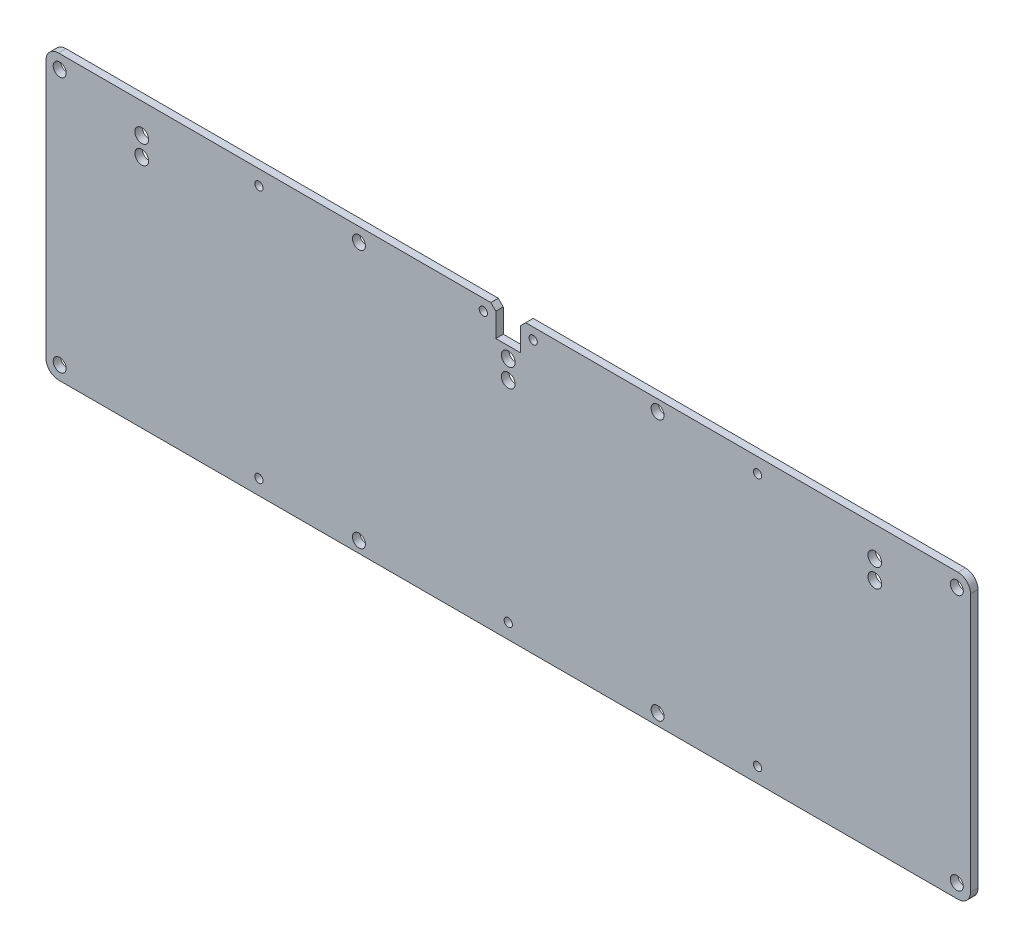
from build123d import *

# Parameters (mm, degrees)
MODEL_R             = 2.6
MODEL_R_2           = 1.65
MODEL_R_3           = 2.75
BOSS_EXTRUDE1_DEPTH = 3


with BuildPart() as part:
    # Model → Boss-Extrude1 (new body)
    with BuildSketch(Plane.XY):
        with BuildLine():
            Line((0, 108.6), (0, 5))
            ThreePointArc((0, 5), (1.464466094, 1.464466094), (5, 0))
            Line((5, 0), (365.775, 0))
            ThreePointArc((365.775, 0), (369.310533906, 1.464466094), (370.775, 5))
            Line((370.775, 5), (370.775, 108.6))
            ThreePointArc((370.775, 108.6), (369.310533906, 112.135533906), (365.775, 113.6))
            Line((365.775, 113.6), (192.387500002, 113.6))
            Line((192.387500002, 113.6), (190.387500002, 111.6))
            Line((190.387500002, 111.6), (190.387500002, 102.1))
            Line((190.387500002, 102.1), (180.387500002, 102.1))
            Line((180.387500002, 102.1), (180.387500001, 111.6))
            Line((180.387500001, 111.6), (178.387500002, 113.6))
            Line((178.387500002, 113.6), (5, 113.6))
            ThreePointArc((5, 113.6), (1.464466094, 112.135533906), (0, 108.6))
        make_face()
        with Locations((5.5, 108.1)):
            Circle(MODEL_R, mode=Mode.SUBTRACT)
        with Locations((5.5, 5.5)):
            Circle(MODEL_R, mode=Mode.SUBTRACT)
        with Locations((365.275, 5.5)):
            Circle(MODEL_R, mode=Mode.SUBTRACT)
        with Locations((365.275, 108.1)):
            Circle(MODEL_R, mode=Mode.SUBTRACT)
        with Locations((125.5, 4.5)):
            Circle(MODEL_R, mode=Mode.SUBTRACT)
        with Locations((195.3875, 109.1)):
            Circle(MODEL_R_2, mode=Mode.SUBTRACT)
        with Locations((175.3875, 109.1)):
            Circle(MODEL_R_2, mode=Mode.SUBTRACT)
        with Locations((38.387499996, 94.1)):
            Circle(MODEL_R_3, mode=Mode.SUBTRACT)
        with Locations((38.3875, 101.6)):
            Circle(MODEL_R_3, mode=Mode.SUBTRACT)
        with Locations((332.387499996, 94.1)):
            Circle(MODEL_R_3, mode=Mode.SUBTRACT)
        with Locations((332.3875, 101.6)):
            Circle(MODEL_R_3, mode=Mode.SUBTRACT)
        with Locations((185.387499995, 90.1)):
            Circle(MODEL_R_3, mode=Mode.SUBTRACT)
        with Locations((185.387499999, 97.6)):
            Circle(MODEL_R_3, mode=Mode.SUBTRACT)
        with Locations((85.3875, 107.6)):
            Circle(MODEL_R_2, mode=Mode.SUBTRACT)
        with Locations((285.3875, 107.6)):
            Circle(MODEL_R_2, mode=Mode.SUBTRACT)
        with Locations((85.3875, 6)):
            Circle(MODEL_R_2, mode=Mode.SUBTRACT)
        with Locations((185.3875, 6)):
            Circle(MODEL_R_2, mode=Mode.SUBTRACT)
        with Locations((285.3875, 6)):
            Circle(MODEL_R_2, mode=Mode.SUBTRACT)
        with Locations((245.275, 4.5)):
            Circle(MODEL_R, mode=Mode.SUBTRACT)
        with Locations((125.499999999, 108.1)):
            Circle(MODEL_R, mode=Mode.SUBTRACT)
        with Locations((245.275, 109.1)):
            Circle(MODEL_R, mode=Mode.SUBTRACT)
    extrude(amount=BOSS_EXTRUDE1_DEPTH)


solid = part.part
